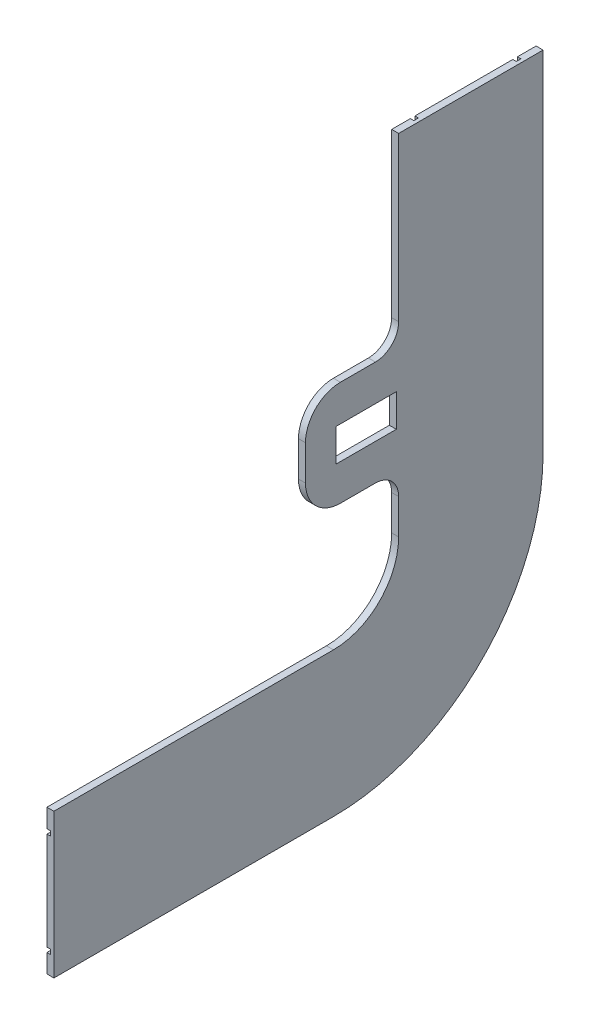
from build123d import *

# Parameters (mm, degrees)
BOSS_EXTRUDE1_DEPTH = 3
CUT_EXTRUDE1_DEPTH  = 1.5
SKETCH5_W           = 40
SKETCH5_H           = 45
BOSS_EXTRUDE2_DEPTH = 3
SKETCH6_W           = 26
SKETCH6_H           = 14
CUT_EXTRUDE2_DEPTH  = 3
FILLET1_R           = 15
SKETCH7_W           = 10.438197785
SKETCH7_H           = 15.5
SKETCH7_W_2         = 18.220797936
BOSS_EXTRUDE3_DEPTH = 3
FILLET2_R           = 10


with BuildPart() as part:
    # Sketch1 → Boss-Extrude1 (new body)
    with BuildSketch(Plane(origin=(0, 0, 0), x_dir=(0, 0, -1), z_dir=(1, 0, 0))):
        with BuildLine():
            Line((0, -28), (-120, -28))
            Line((-120, -28), (-120, -90))
            Line((-120, -90), (0, -90))
            ThreePointArc((0, -90), (63.639610307, -63.639610307), (90, 0))
            Line((90, 0), (90, 150))
            Line((90, 150), (28, 150))
            Line((28, 150), (28, 0))
            ThreePointArc((28, 0), (19.798989873, -19.798989873), (0, -28))
        make_face()
    extrude(amount=BOSS_EXTRUDE1_DEPTH)

    # Sketch2 → Cut-Extrude1 (cut)
    with BuildSketch(Plane(origin=(3, 0, 0), x_dir=(0, 0, -1), z_dir=(1, 0, 0))):
        with BuildLine():
            Line((0, -38), (-120, -38))
            Line((-120, -38), (-120, -36))
            Line((-120, -36), (0, -36))
            ThreePointArc((0, -36), (25.455844123, -25.455844123), (36, 0))
            Line((36, 0), (36, 150))
            Line((36, 150), (38, 150))
            Line((38, 150), (38, 0))
            ThreePointArc((38, 0), (26.870057685, -26.870057685), (0, -38))
        make_face()
        with BuildLine():
            Line((0, -80), (-120, -80))
            Line((-120, -80), (-120, -82))
            Line((-120, -82), (0, -82))
            ThreePointArc((0, -82), (57.982756057, -57.982756057), (82, 0))
            Line((82, 0), (82, 150))
            Line((82, 150), (80, 150))
            Line((80, 150), (80, 0))
            ThreePointArc((80, 0), (56.568542495, -56.568542495), (0, -80))
        make_face()
    extrude(amount=-CUT_EXTRUDE1_DEPTH, mode=Mode.SUBTRACT)


with BuildPart() as body_2:
    # Mirror1: mirrored copy
    add(part.part.mirror(Plane(origin=(3, 0, 0), x_dir=(0, 0, 1), z_dir=(1, 0, 0))))



with BuildPart() as body_2_2:
    # Sketch5 → Boss-Extrude2 (new body)
    with BuildSketch(Plane(origin=(6, 0, 0), x_dir=(0, 0, -1), z_dir=(1, 0, 0))):
        with Locations((8, 47.5)):
            Rectangle(SKETCH5_W, SKETCH5_H)
    extrude(amount=-BOSS_EXTRUDE2_DEPTH)

    # Sketch6 → Cut-Extrude2 (cut)
    with BuildSketch(Plane(origin=(6, 0, 0), x_dir=(0, 0, -1), z_dir=(1, 0, 0))):
        with Locations((14, 47.5)):
            Rectangle(SKETCH6_W, SKETCH6_H)
    extrude(amount=-CUT_EXTRUDE2_DEPTH, mode=Mode.SUBTRACT)

    # Fillet1
    fillet1_edges = [body_2_2.edges().sort_by_distance(p)[0] for p in [
        (4.5, 25, 12),
        (4.5, 70, 12),
    ]]
    fillet(fillet1_edges, radius=FILLET1_R)


with BuildPart() as body_2_1:
    add(body_2.part)

    add(body_2_2.part)  # Boss-Extrude3 merges body 2 2
    # Sketch7 → Boss-Extrude3 (add)
    with BuildSketch(Plane(origin=(6, 0, 0), x_dir=(0, 0, -1), z_dir=(1, 0, 0))):
        with Locations((26.467997442, 62.25)):
            Rectangle(SKETCH7_W, SKETCH7_H)
        with Locations((28.397040912, 32.75)):
            Rectangle(SKETCH7_W_2, SKETCH7_H)
    extrude(amount=-BOSS_EXTRUDE3_DEPTH)

    # Fillet2
    fillet2_edges = [body_2_1.edges().sort_by_distance(p)[0] for p in [
        (4.5, 70, -28),
        (4.5, 25, -28),
    ]]
    fillet(fillet2_edges, radius=FILLET2_R)


solid = body_2_1.part
